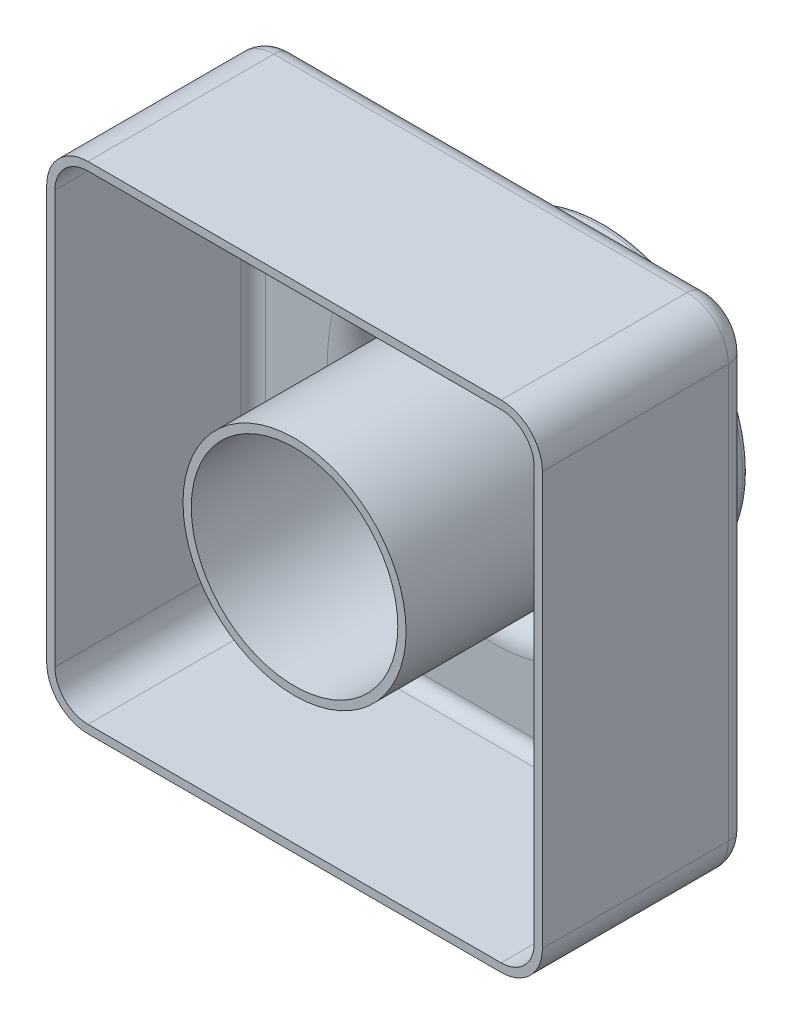
from build123d import *

# Parameters (mm, degrees)
SKETCH3_W           = 120
SKETCH3_H           = 120
BOSS_EXTRUDE2_DEPTH = 50
SKETCH6_R           = 35
BOSS_EXTRUDE3_DEPTH = 25
SKETCH8_R           = 25
CUT_EXTRUDE1_DEPTH  = 80
FILLET1_R           = 1.5
FILLET2_R           = 10
FILLET3_R           = 5
SHELL1_T            = -2


with BuildPart() as part:
    # Sketch3 → Boss-Extrude2 (new body)
    with BuildSketch(Plane.XY):
        with Locations((60, -60)):
            Rectangle(SKETCH3_W, SKETCH3_H)
    extrude(amount=BOSS_EXTRUDE2_DEPTH)

    # Sketch6 → Boss-Extrude3 (add)
    with BuildSketch(Plane(origin=(0, 0, 0), x_dir=(-1, 0, 0), z_dir=(0, 0, -1))):
        with Locations((-60, -60)):
            Circle(SKETCH6_R)
    extrude(amount=BOSS_EXTRUDE3_DEPTH)

    # Sketch8 → Cut-Extrude1 (cut)
    with BuildSketch(Plane(origin=(0, 0, -25), x_dir=(-1, 0, 0), z_dir=(0, 0, -1))):
        with Locations((-60, -60)):
            Circle(SKETCH8_R)
    extrude(amount=-CUT_EXTRUDE1_DEPTH, mode=Mode.SUBTRACT)

    # Fillet1
    fillet1_edges = [part.edges().sort_by_distance(p)[0] for p in [
        (95, -60, -25),
        (85, -60, -25),
    ]]
    fillet(fillet1_edges, radius=FILLET1_R)

    # Fillet2
    fillet2_edges = [part.edges().sort_by_distance(p)[0] for p in [
        (0, 0, 25),
        (120, 0, 25),
        (120, -120, 25),
        (0, -120, 25),
    ]]
    fillet(fillet2_edges, radius=FILLET2_R)

    # Fillet3
    fillet3_edges = [part.edges().sort_by_distance(p)[0] for p in [
        (95, -60, 0),
        (120, -60, 0),
        (0, -60, 0),
        (60, 0, 0),
        (60, -120, 0),
        (2.928932188, -117.071067812, 0),
        (117.071067812, -2.928932188, 0),
        (2.928932188, -2.928932188, 0),
        (117.071067812, -117.071067812, 0),
    ]]
    fillet(fillet3_edges, radius=FILLET3_R)

    # Shell1
    shell1_openings = [part.faces().sort_by_distance(p)[0] for p in [
        (85, -60, 50),
    ]]
    offset(amount=SHELL1_T, openings=shell1_openings, kind=Kind.INTERSECTION)


solid = part.part
